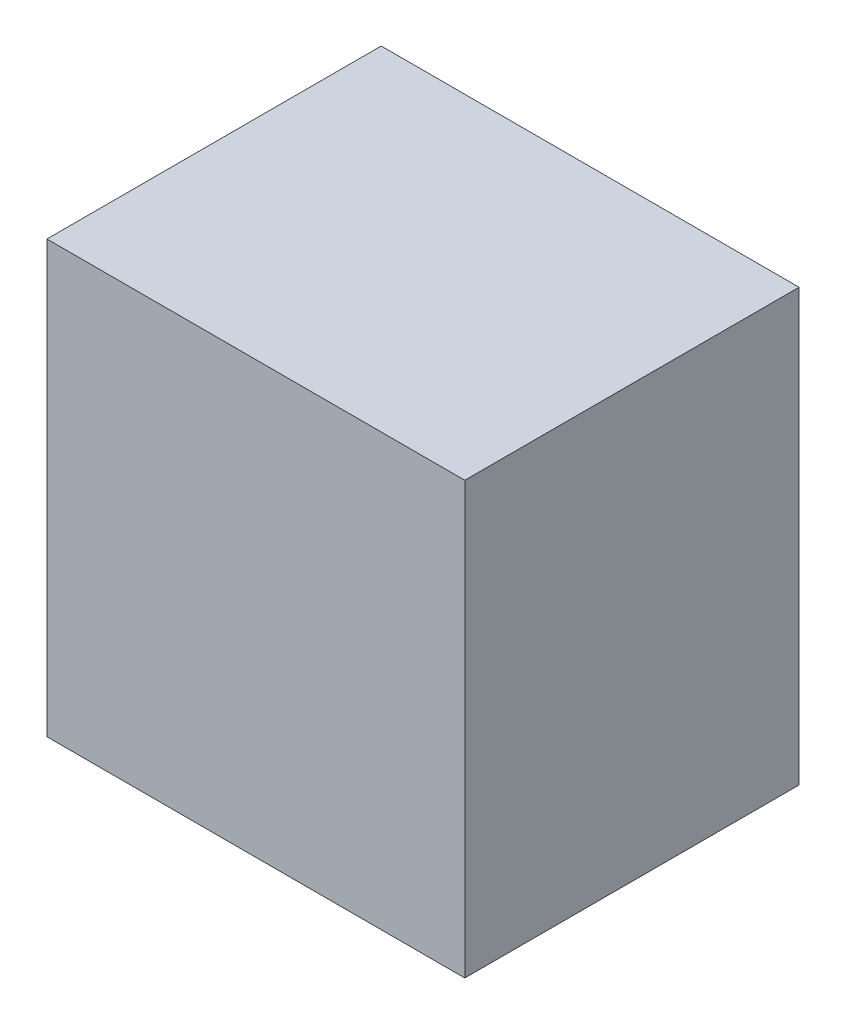
from build123d import *

# Parameters (mm, degrees)
SKETCH1_W           = 190
SKETCH1_H           = 152
BOSS_EXTRUDE1_DEPTH = 196


with BuildPart() as part:
    # Sketch1 → Boss-Extrude1 (new body)
    with BuildSketch(Plane(origin=(0, 0, 0), x_dir=(1, 0, 0), z_dir=(0, 1, 0))):
        with Locations((95, 76)):
            Rectangle(SKETCH1_W, SKETCH1_H)
    extrude(amount=BOSS_EXTRUDE1_DEPTH)


solid = part.part
